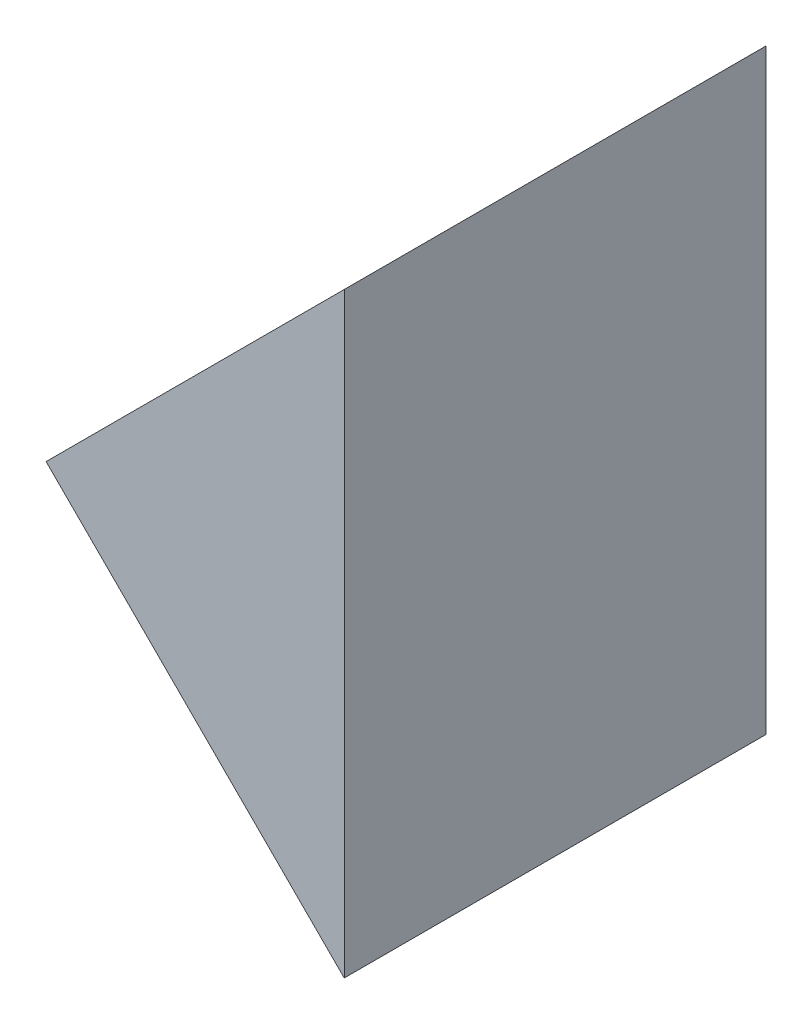
from build123d import *

# Parameters (mm, degrees)
EXTRUDE_1_DEPTH = 50


with BuildPart() as part:
    # 草图1 → 凸台-拉伸1 (new body)
    with BuildSketch(Plane.XY):
        Polygon((554.766699526, 137.756925528), (590.122038585, 173.112264588), (590.122038585, 102.401586469), align=None)
    extrude(amount=EXTRUDE_1_DEPTH)


solid = part.part
